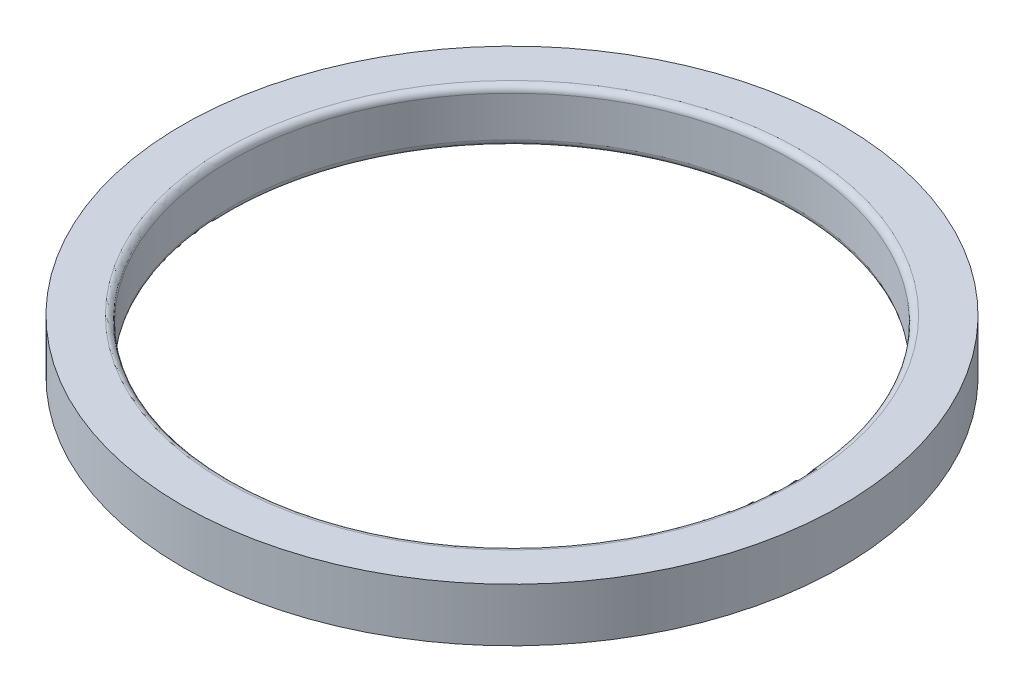
from build123d import *

# Parameters (mm, degrees)
SKETCH_1_R      = 10.2
SKETCH_1_R_2    = 8.7
EXTRUDE_1_DEPTH = 1.65
FILLET_1_R      = 0.2


with BuildPart() as part:
    # 草图1 → 凸台-拉伸1 (new body)
    with BuildSketch(Plane(origin=(0, 0, 0), x_dir=(1, 0, 0), z_dir=(0, 1, 0))):
        Circle(SKETCH_1_R)
        Circle(SKETCH_1_R_2, mode=Mode.SUBTRACT)
    extrude(amount=EXTRUDE_1_DEPTH)

    # 圆角1
    fillet_1_edges = [part.edges().sort_by_distance(p)[0] for p in [
        (-8.7, 0, 0),
        (-8.7, 1.65, 0),
    ]]
    fillet(fillet_1_edges, radius=FILLET_1_R)


solid = part.part
